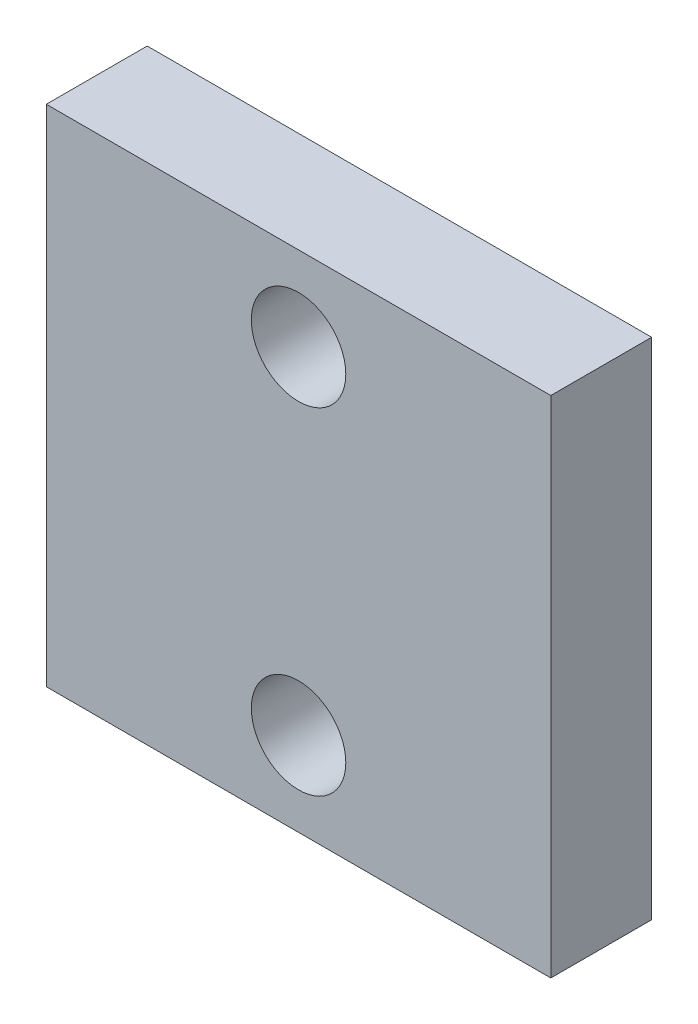
from build123d import *

# Parameters (mm, degrees)
ESQUISSE1_W        = 60
ESQUISSE1_H        = 60
ESQUISSE1_R        = 5.61862085
BOSS_EXTRU_2_DEPTH = 12


with BuildPart() as part:
    # Esquisse1 → Boss.-Extru.2 (new body)
    with BuildSketch(Plane.XY):
        Rectangle(ESQUISSE1_W, ESQUISSE1_H)
        with Locations((0, 20)):
            Circle(ESQUISSE1_R, mode=Mode.SUBTRACT)
        with Locations((0, -20)):
            Circle(ESQUISSE1_R, mode=Mode.SUBTRACT)
    extrude(amount=BOSS_EXTRU_2_DEPTH)


solid = part.part
